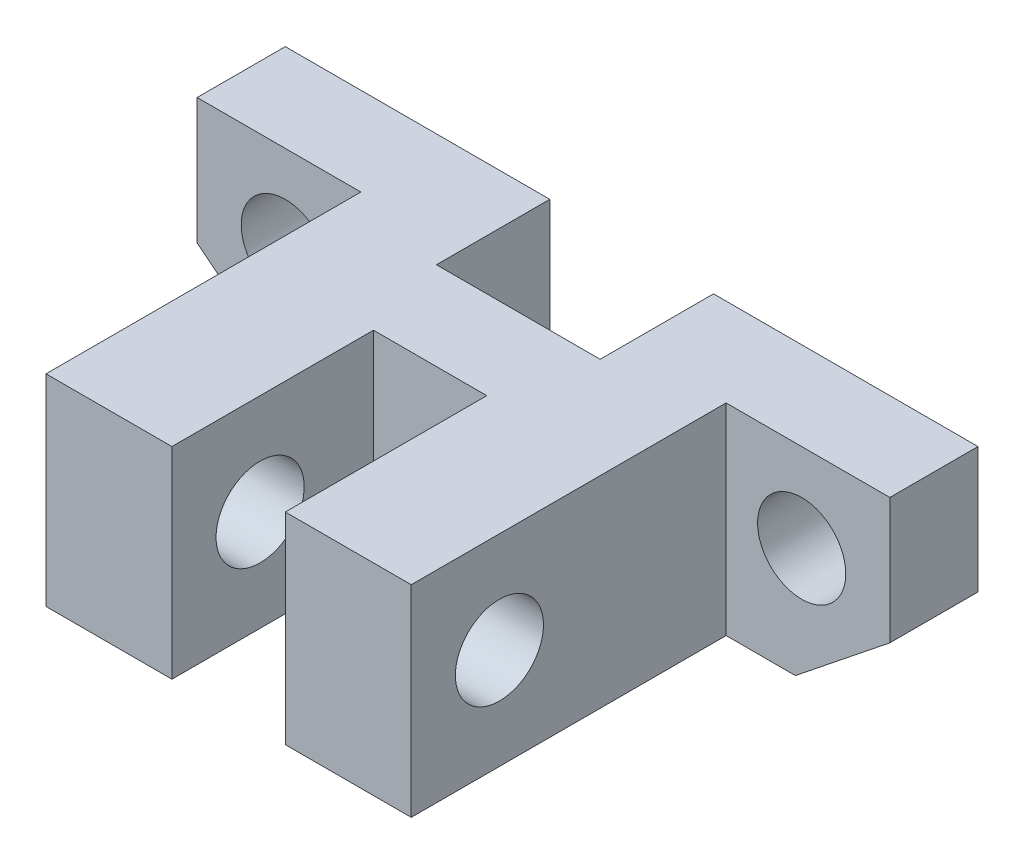
from build123d import *

# Parameters (mm, degrees)
SALIENTE_EXTRUIR1_DEPTH = 32
CROQUIS3_W              = 28.149246734
CROQUIS3_H              = 33.455515618
CORTAR_EXTRUIR1_DEPTH   = 13
CROQUIS4_W              = 32.272758708
CROQUIS4_H              = 29.27783323
CORTAR_EXTRUIR2_DEPTH   = 13
CROQUIS5_W              = 13
CROQUIS5_H              = 9
CORTAR_EXTRUIR3_DEPTH   = 17
CROQUIS6_W              = 9
CROQUIS6_H              = 23
CORTAR_EXTRUIR4_DEPTH   = 17
CROQUIS7_R              = 3.5
CORTAR_EXTRUIR5_DEPTH   = 43
CROQUIS9_R              = 3.5
CORTAR_EXTRUIR6_DEPTH   = 8


with BuildPart() as part:
    # Croquis1 → Saliente-Extruir1 (new body)
    with BuildSketch(Plane.XY):
        Polygon((-20, -11), (-27.5, -5), (-27.5, 5), (27.5, 5), (27.5, -5), (20, -11), align=None)
    extrude(amount=SALIENTE_EXTRUIR1_DEPTH)

    # Croquis3 → Cortar-Extruir1 (cut)
    with BuildSketch(Plane(origin=(27.5, 0, 0), x_dir=(0, 0, -1), z_dir=(1, 0, 0))):
        with Locations((-21.074623367, 0)):
            Rectangle(CROQUIS3_W, CROQUIS3_H)
    extrude(amount=-CORTAR_EXTRUIR1_DEPTH, mode=Mode.SUBTRACT)

    # Croquis4 → Cortar-Extruir2 (cut)
    with BuildSketch(Plane.ZY.offset(27.5)):
        with Locations((23.136379354, -3.846869201)):
            Rectangle(CROQUIS4_W, CROQUIS4_H)
    extrude(amount=-CORTAR_EXTRUIR2_DEPTH, mode=Mode.SUBTRACT)

    # Croquis5 → Cortar-Extruir3 (cut, through all)
    with BuildSketch(Plane.XZ.offset(11)):
        with Locations((0, 4.5)):
            Rectangle(CROQUIS5_W, CROQUIS5_H)
    extrude(amount=-CORTAR_EXTRUIR3_DEPTH, mode=Mode.SUBTRACT)

    # Croquis6 → Cortar-Extruir4 (cut, through all)
    with BuildSketch(Plane.XZ.offset(11)):
        with Locations((0, 27.5)):
            Rectangle(CROQUIS6_W, CROQUIS6_H)
    extrude(amount=-CORTAR_EXTRUIR4_DEPTH, mode=Mode.SUBTRACT)

    # Croquis7 → Cortar-Extruir5 (cut, through all)
    with BuildSketch(Plane(origin=(14.5, 0, 0), x_dir=(0, 0, -1), z_dir=(1, 0, 0))):
        with Locations((-25, -3)):
            Circle(CROQUIS7_R)
    extrude(amount=-CORTAR_EXTRUIR5_DEPTH, mode=Mode.SUBTRACT)

    # Croquis9 → Cortar-Extruir6 (cut, through all)
    with BuildSketch(Plane.XY.offset(7)):
        with Locations((20.5, -2)):
            Circle(CROQUIS9_R)
        with Locations((-20.5, -2)):
            Circle(CROQUIS9_R)
    extrude(amount=-CORTAR_EXTRUIR6_DEPTH, mode=Mode.SUBTRACT)


solid = part.part
